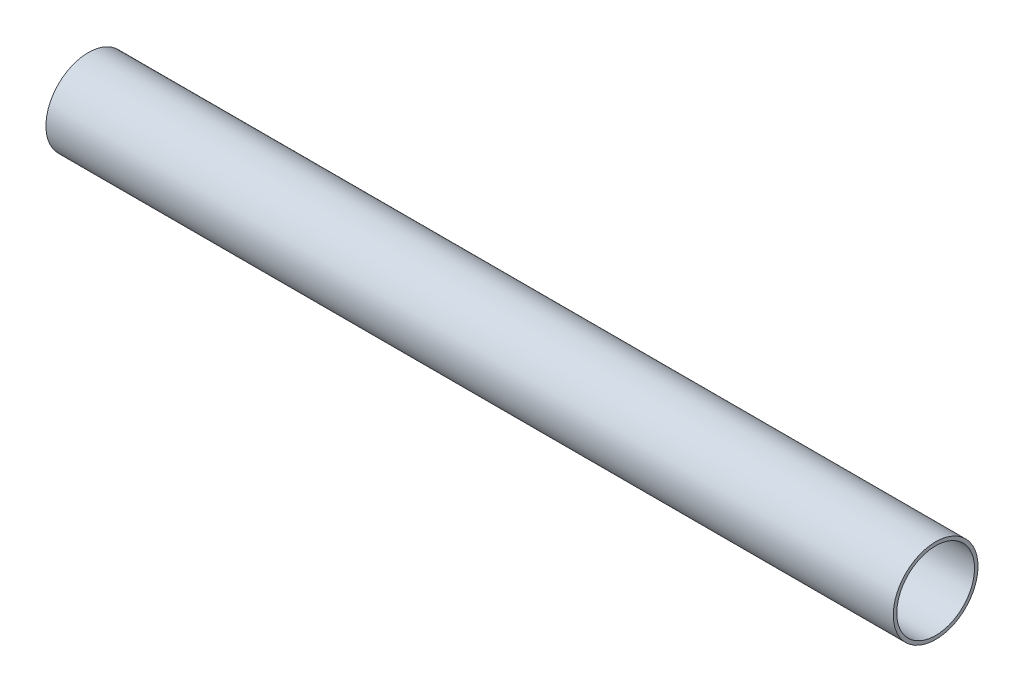
from build123d import *

# Parameters (mm, degrees)
SKETCH1_R           = 16
SKETCH1_R_2         = 14.68
BOSS_EXTRUDE1_DEPTH = 160


with BuildPart() as part:
    # Sketch1 → Boss-Extrude1 (new body, symmetric)
    with BuildSketch(Plane(origin=(0, 0, 0), x_dir=(0, 0, -1), z_dir=(1, 0, 0))):
        Circle(SKETCH1_R)
        Circle(SKETCH1_R_2, mode=Mode.SUBTRACT)
    extrude(amount=BOSS_EXTRUDE1_DEPTH, both=True)


solid = part.part
